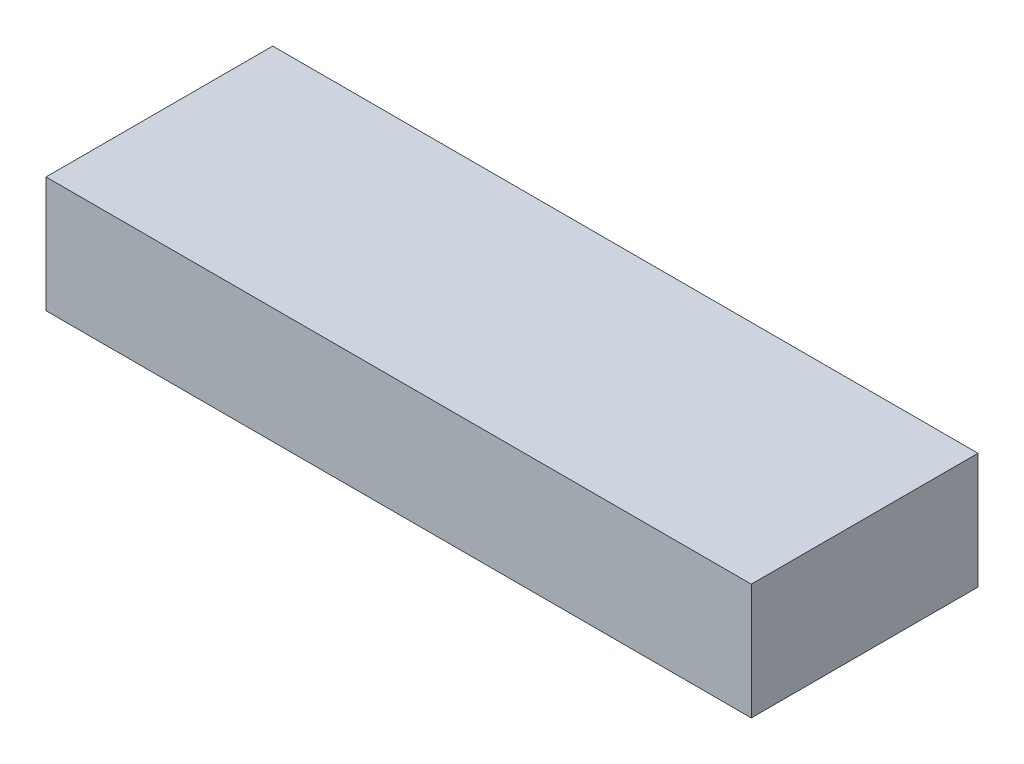
from build123d import *

# Parameters (mm, degrees)
SCHIZZO1_W                   = 140
SCHIZZO1_H                   = 45
ESTRUSIONE_ESTRUSIONE1_DEPTH = 23


with BuildPart() as part:
    # Schizzo1 → Estrusione-Estrusione1 (new body)
    with BuildSketch(Plane(origin=(0, 0, 0), x_dir=(1, 0, 0), z_dir=(0, 1, 0))):
        Rectangle(SCHIZZO1_W, SCHIZZO1_H)
    extrude(amount=ESTRUSIONE_ESTRUSIONE1_DEPTH)


solid = part.part
